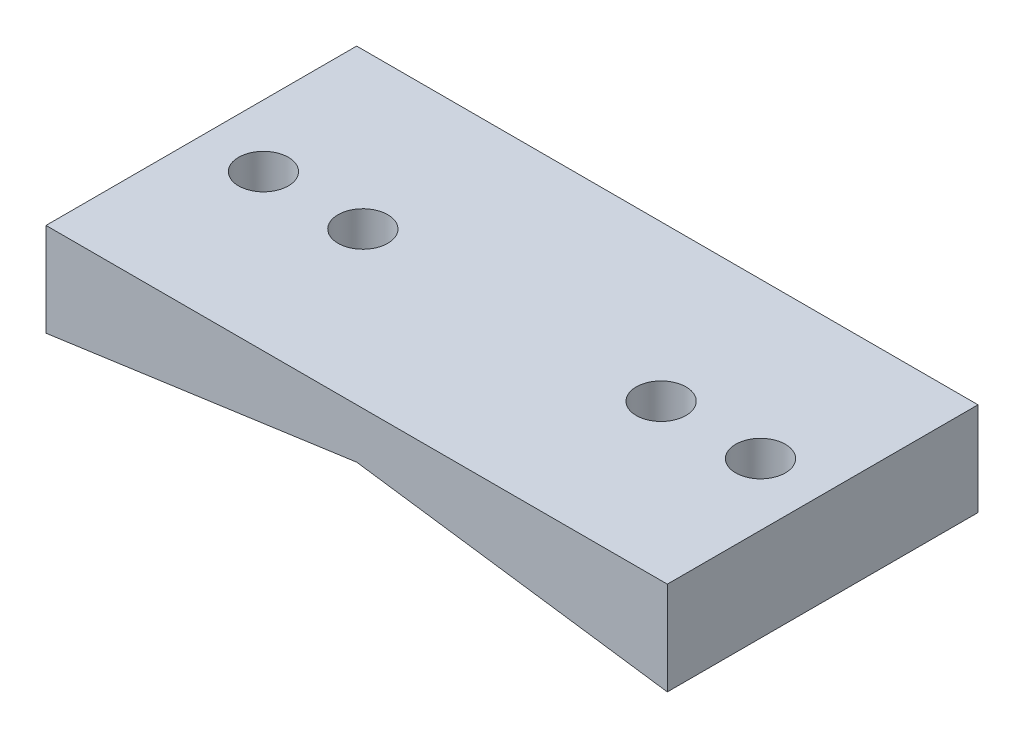
from build123d import *

# Parameters (mm, degrees)
ESQUISSE1_W                                 = 100
ESQUISSE1_H                                 = 20
BOSS_EXTRU_1_DEPTH                          = 25
FRAISAGE_POUR_VIS_T_TE_FRAIS_E_M81_AT_COUNT = 2
FRAISAGE_POUR_VIS_T_TE_FRAIS_E_M81_AT_PITCH = 48
DIAM_TRE_DU_PER_AGE_8_0_8_1_D               = 8
ENL_V_MAT_EXTRU_1_DEPTH                     = 51


with BuildPart() as part:
    # Esquisse1 → Boss.-Extru.1 (new body, symmetric)
    with BuildSketch(Plane.XY):
        Rectangle(ESQUISSE1_W, ESQUISSE1_H)
    extrude(amount=BOSS_EXTRU_1_DEPTH, both=True)

    # Esquisse13 → Fraisage pour vis à tête fraisée M81 (revolve, cut)
    with BuildSketch(Plane(origin=(-24, -10, 0), x_dir=(0, 0, -1), z_dir=(1, 0, 0))):
        Polygon((0, 0), (0, 20), (4, 20), (4, 14), (8, 10), (8, 0), align=None)
    fraisage_pour_vis_t_te_frais_e_m81 = revolve(axis=Axis((-24, -16.35, 0), (0, 1, 0)), mode=Mode.SUBTRACT)

    # Fraisage pour vis à tête fraisée M81 at: Fraisage pour vis à tête fraisée M81 ×2
    with Locations(*[(i * FRAISAGE_POUR_VIS_T_TE_FRAIS_E_M81_AT_PITCH, 0, 0) for i in range(1, FRAISAGE_POUR_VIS_T_TE_FRAIS_E_M81_AT_COUNT)]):
        add(fraisage_pour_vis_t_te_frais_e_m81, mode=Mode.SUBTRACT)

    # Diamètre du perçage Ø8.0 (8)1 (through all)
    with Locations(Plane(origin=(0, -10, 0), x_dir=(-1, 0, 0), z_dir=(0, -1, 0))):
        with Locations((-40, 0), (40, 0)):
            Hole(DIAM_TRE_DU_PER_AGE_8_0_8_1_D / 2)

    # Esquisse16 → Enlèv. mat.-Extru.1 (cut, through all)
    with BuildSketch(Plane(origin=(0, 0, -25), x_dir=(-1, 0, 0), z_dir=(0, 0, -1))):
        Polygon((0, 2), (-50, -5.027041735), (-50, -10), (50, -10), (50, -5.027041735), align=None)
    extrude(amount=-ENL_V_MAT_EXTRU_1_DEPTH, mode=Mode.SUBTRACT)


solid = part.part
